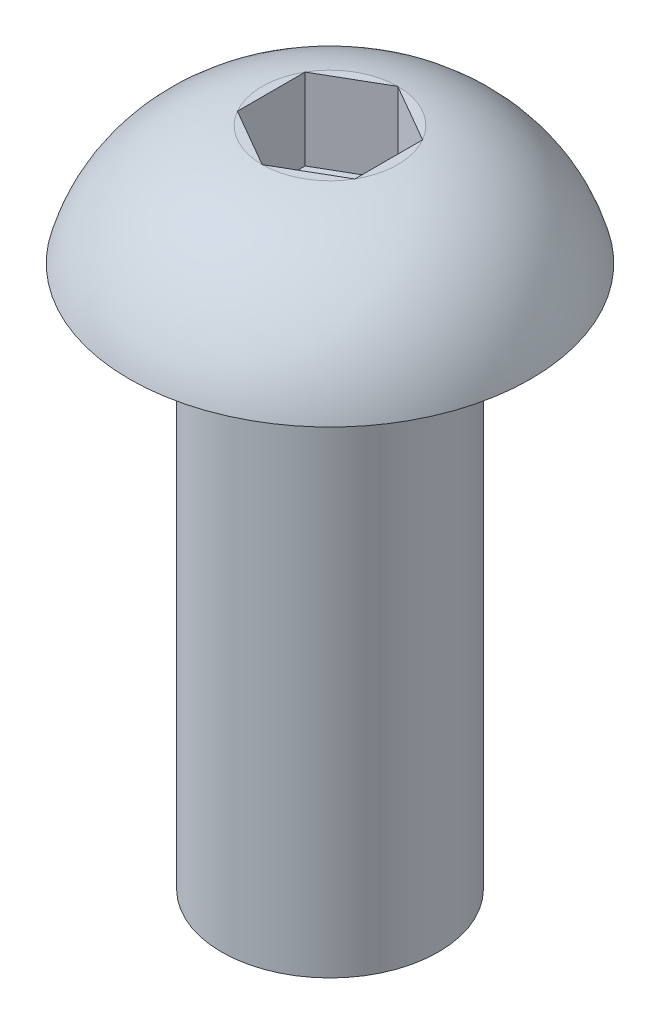
from build123d import *

# Parameters (mm, degrees)
SKETCH2_R           = 2
BOSS_EXTRUDE1_DEPTH = 10
CUT_EXTRUDE1_DEPTH  = 1.5


with BuildPart() as part:
    # Sketch1 → Revolve1 (revolve)
    with BuildSketch(Plane(origin=(0, 0, 0), x_dir=(0, 0, -1), z_dir=(1, 0, 0))):
        with BuildLine():
            Line((0, 0), (0, 2.2))
            Line((0, 2.2), (-1.25, 2.2))
            ThreePointArc((-1.25, 2.2), (-2.80380946, 1.466174172), (-3.7, 0))
            Line((-3.7, 0), (0, 0))
        make_face()
    revolve(axis=Axis((0, 4.725289413, 0), (0, -1, 0)))

    # Sketch2 → Boss-Extrude1 (add)
    with BuildSketch(Plane.XZ):
        Circle(SKETCH2_R)
    extrude(amount=BOSS_EXTRUDE1_DEPTH)

    # Sketch3 → Cut-Extrude1 (cut)
    with BuildSketch(Plane(origin=(0, 2.2, 0), x_dir=(1, 0, 0), z_dir=(0, 1, 0))):
        Polygon((0, 1.25), (-1.082531755, 0.625), (-1.082531755, -0.625), (0, -1.25), (1.082531755, -0.625), (1.082531755, 0.625), align=None)
    extrude(amount=-CUT_EXTRUDE1_DEPTH, mode=Mode.SUBTRACT)


solid = part.part
